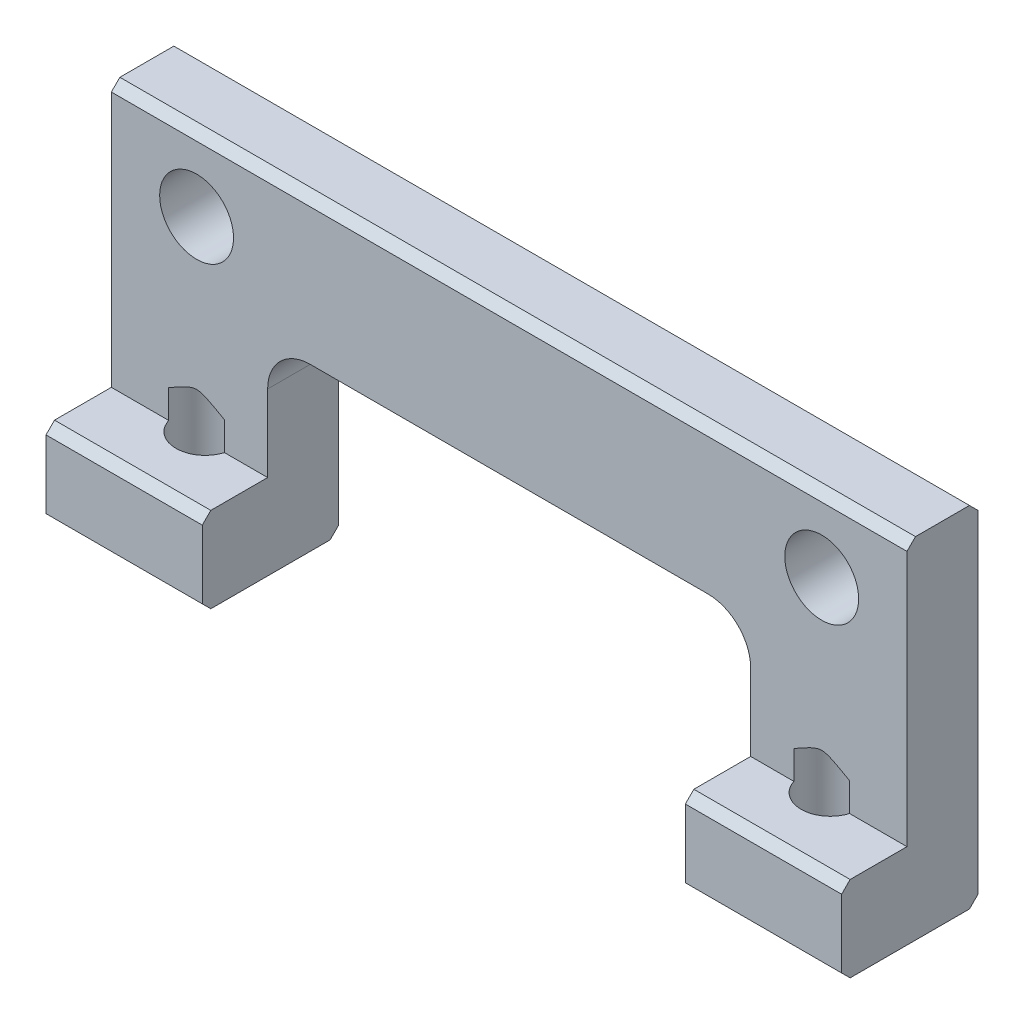
from build123d import *

# Parameters (mm, degrees)
SKETCH1_W                        = 5.5
SKETCH1_H                        = 12.3
BOSS_EXTRUDE1_DEPTH              = 4.8
SKETCH2_W                        = 2.3
SKETCH2_H                        = 9.3
CUT_EXTRUDE1_DEPTH               = 6.5
SKETCH3_W                        = 2.5
SKETCH3_H                        = 5.1
BOSS_EXTRUDE2_DEPTH              = 22.5
SKETCH4_W                        = 5.5
SKETCH4_H                        = 2.5
BOSS_EXTRUDE3_DEPTH              = 7.2
SKETCH5_W                        = 5.5
SKETCH5_H                        = 3
BOSS_EXTRUDE4_DEPTH              = 2.3
F_2_6_2_6_DIAMETER_HOLE1_D       = 2.6
F_2_6_2_6_DIAMETER_HOLE1_DEPTH   = 4.8
F_2_05_2_05_DIAMETER_HOLE1_D     = 2.05
F_2_05_2_05_DIAMETER_HOLE1_DEPTH = 4
F_2_05_2_05_DIAMETER_HOLE1_TIP   = 0.615882135
CHAMFER1_SIZE                    = 0.3
CHAMFER2_SIZE                    = 0.2
FILLET1_R                        = 1.5


with BuildPart() as part:
    # Sketch1 → Boss-Extrude1 (new body)
    with BuildSketch(Plane(origin=(0, 0, -2.5), x_dir=(-1, 0, 0), z_dir=(0, 0, -1))):
        with Locations((-11.25, 6.15)):
            Rectangle(SKETCH1_W, SKETCH1_H)
    extrude(amount=-BOSS_EXTRUDE1_DEPTH)

    # Sketch2 → Cut-Extrude1 (cut, through all)
    with BuildSketch(Plane.ZY.offset(-8.5)):
        with Locations((1.15, 7.65)):
            Rectangle(SKETCH2_W, SKETCH2_H)
    extrude(amount=-CUT_EXTRUDE1_DEPTH, mode=Mode.SUBTRACT)

    # Sketch3 → Boss-Extrude2 (add)
    with BuildSketch(Plane.ZY.offset(-8.5)):
        with Locations((-1.25, 9.75)):
            Rectangle(SKETCH3_W, SKETCH3_H)
    extrude(amount=BOSS_EXTRUDE2_DEPTH)

    # Sketch4 → Boss-Extrude3 (add)
    with BuildSketch(Plane.XZ.offset(-7.2)):
        with Locations((-11.25, -1.25)):
            Rectangle(SKETCH4_W, SKETCH4_H)
    extrude(amount=BOSS_EXTRUDE3_DEPTH)

    # Sketch5 → Boss-Extrude4 (add)
    with BuildSketch(Plane.XY):
        with Locations((-11.25, 1.5)):
            Rectangle(SKETCH5_W, SKETCH5_H)
    extrude(amount=BOSS_EXTRUDE4_DEPTH)

    # Ø2.6 (2.6) Diameter Hole1
    with Locations(Plane(origin=(0, 0, -2.5), x_dir=(-1, 0, 0), z_dir=(0, 0, -1))):
        with Locations((11, 9.7), (-11, 9.7)):
            Hole(F_2_6_2_6_DIAMETER_HOLE1_D / 2, depth=F_2_6_2_6_DIAMETER_HOLE1_DEPTH)

    # Ø2.05 (2.05) Diameter Hole1
    with Locations(Plane(origin=(0, 0, 0), x_dir=(-1, 0, 0), z_dir=(0, -1, 0))):
        with Locations((-11, 0.3), (11, 0.3)):
            Hole(F_2_05_2_05_DIAMETER_HOLE1_D / 2, depth=F_2_05_2_05_DIAMETER_HOLE1_DEPTH)
            with Locations((0, 0, -(F_2_05_2_05_DIAMETER_HOLE1_DEPTH + F_2_05_2_05_DIAMETER_HOLE1_TIP / 2))):  # 118° drill point
                Cone(0, F_2_05_2_05_DIAMETER_HOLE1_D / 2, F_2_05_2_05_DIAMETER_HOLE1_TIP, mode=Mode.SUBTRACT)

    # Chamfer1
    chamfer1_edges = [part.edges().sort_by_distance(p)[0] for p in [
        (11.25, 0, -2.5),
        (-11.25, 0, -2.5),
        (9.975, 0, -0.3),
        (0, 12.3, 0),
        (0, 12.3, -2.5),
        (-12.025, 0, -0.3),
        (9.7, 9.7, -2.5),
        (11.25, 0, 2.3),
        (-11.25, 0, 2.3),
        (11.25, 3, 2.3),
        (-11.25, 3, 2.3),
    ]]
    chamfer(chamfer1_edges, length=CHAMFER1_SIZE)

    # Chamfer2
    chamfer2_edges = [part.edges().sort_by_distance(p)[0] for p in [
        (-12.3, 9.7, -2.5),
    ]]
    chamfer(chamfer2_edges, length=CHAMFER2_SIZE)

    # Fillet1
    fillet1_edges = [part.edges().sort_by_distance(p)[0] for p in [
        (-8.5, 7.2, -1.25),
        (8.5, 7.2, -1.25),
    ]]
    fillet(fillet1_edges, radius=FILLET1_R)


solid = part.part
